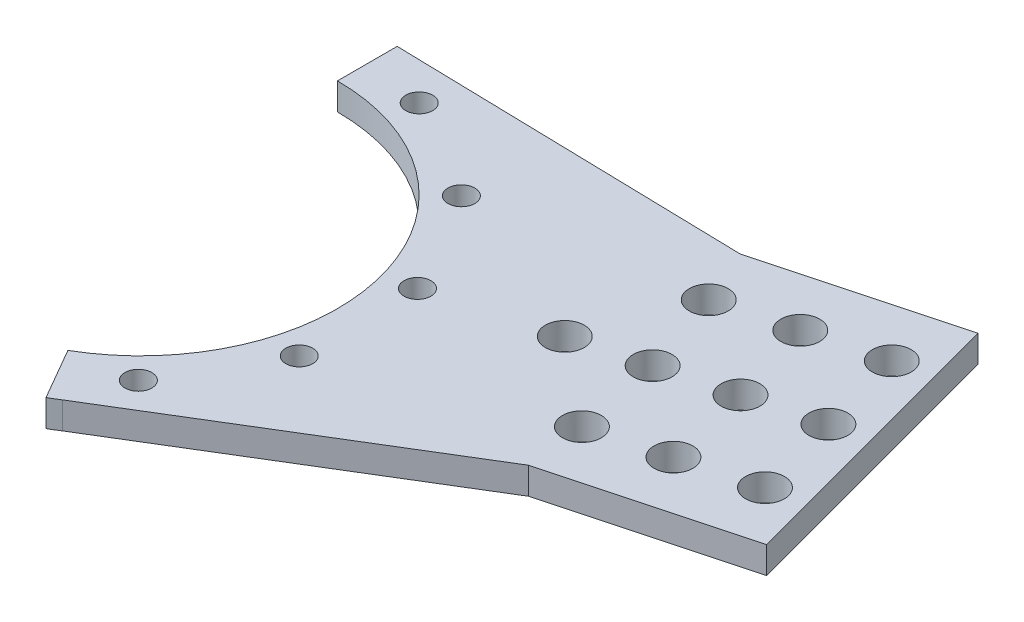
from build123d import *

# Parameters (mm, degrees)
BOSS_EXTRUDE1_DEPTH             = 2.25
BOSS_EXTRUDE2_DEPTH             = 2.25
BOSS_EXTRUDE3_DEPTH             = 2.25
CUT_EXTRUDE1_START              = -5.5
SKETCH2_R                       = 2.25
CUT_EXTRUDE1_DEPTH              = 6.5
CIRPATTERN1_COUNT               = 3
CIRPATTERN1_ANGLE               = 60
CIRPATTERN1_THE_OTHER_WAY_COUNT = 3
CIRPATTERN1_THE_OTHER_WAY_ANGLE = 60
CUT_EXTRUDE2_START              = -5.5
SKETCH6_R                       = 3.25
CUT_EXTRUDE2_DEPTH              = 6.5
LPATTERN1_COUNT                 = 3
LPATTERN1_PITCH                 = 12.5
SKETCH7_R                       = 3.25
CUT_EXTRUDE3_DEPTH              = 10
LPATTERN2_COUNT                 = 4
LPATTERN2_PITCH                 = 12


with BuildPart() as part:
    # Sketch1 → Boss-Extrude1 (new body, symmetric)
    with BuildSketch(Plane(origin=(0, 0, 0), x_dir=(1, 0, 0), z_dir=(0, 1, 0))):
        with BuildLine():
            Line((0, 33), (0, 43))
            ThreePointArc((0, 43), (41.53481053, 11.129218939), (21.5, -37.239092363))
            Line((21.5, -37.239092363), (16.5, -28.578838325))
            ThreePointArc((16.5, -28.578838325), (31.875552268, 8.541028488), (0, 33))
        make_face()
    extrude(amount=BOSS_EXTRUDE1_DEPTH, both=True)

    # Sketch4 → Boss-Extrude2 (add, symmetric)
    with BuildSketch(Plane(origin=(0, 0, 0), x_dir=(1, 0, 0), z_dir=(0, 1, 0))):
        Polygon((90.122106501, 50.030050167), (25.40507614, 32.689174146), (38.346028395, -15.607117169), (103.063058756, 1.733758853), align=None)
    extrude(amount=BOSS_EXTRUDE2_DEPTH, both=True)

    # Sketch5 → Boss-Extrude3 (add, symmetric)
    with BuildSketch(Plane(origin=(0, 0, 0), x_dir=(1, 0, 0), z_dir=(0, 1, 0))):
        Polygon((0, 43), (58.722616268, 41.616582117), (27.323126035, 33.203114066), align=None)
        Polygon((71.663568523, -6.679709198), (40.26407829, -15.093177248), (21.5, -37.239092363), align=None)
    extrude(amount=BOSS_EXTRUDE3_DEPTH, both=True)

    # Sketch2 → Cut-Extrude1 (cut)
    with BuildSketch(Plane(origin=(0, 2.25, 0), x_dir=(1, 0, 0), z_dir=(0, 1, 0)).offset(CUT_EXTRUDE1_START)):
        with Locations((36.757261811, 9.638656763)):
            Circle(SKETCH2_R)
    cut_extrude1 = extrude(amount=CUT_EXTRUDE1_DEPTH, mode=Mode.SUBTRACT)

    # CirPattern1: Cut-Extrude1 ×3 about axis
    cirpattern1_axis = Axis((0, 0, 0), (0, -1, 0))
    for i in range(1, CIRPATTERN1_COUNT):
        add(cut_extrude1.rotate(cirpattern1_axis, i * CIRPATTERN1_ANGLE / (CIRPATTERN1_COUNT - 1)), mode=Mode.SUBTRACT)

    # CirPattern1 the other way: Cut-Extrude1 ×3 about axis
    cirpattern1_the_other_way_axis = Axis((0, 0, 0), (0, 1, 0))
    for i in range(1, CIRPATTERN1_THE_OTHER_WAY_COUNT):
        add(cut_extrude1.rotate(cirpattern1_the_other_way_axis, i * CIRPATTERN1_THE_OTHER_WAY_ANGLE / (CIRPATTERN1_THE_OTHER_WAY_COUNT - 1)), mode=Mode.SUBTRACT)

    # Sketch6 → Cut-Extrude2 (cut)
    with BuildSketch(Plane(origin=(0, 2.25, 0), x_dir=(1, 0, 0), z_dir=(0, 1, 0)).offset(CUT_EXTRUDE2_START)):
        with Locations((94.679313348, 9.840102845)):
            Circle(SKETCH6_R)
        with Locations((86.914741995, 38.817877634)):
            Circle(SKETCH6_R)
    cut_extrude2 = extrude(amount=CUT_EXTRUDE2_DEPTH, mode=Mode.SUBTRACT)

    # LPattern1: Cut-Extrude2 ×3
    with Locations(*[Vector(-0.965925826, 0, 0.258819045) * (i * LPATTERN1_PITCH) for i in range(1, LPATTERN1_COUNT)]):
        add(cut_extrude2, mode=Mode.SUBTRACT)

    # Sketch7 → Cut-Extrude3 (cut)
    with BuildSketch(Plane(origin=(0, 2.25, 0), x_dir=(1, 0, 0), z_dir=(0, 1, 0))):
        with Locations((90.797027671, 24.32899024)):
            Circle(SKETCH7_R)
    cut_extrude3 = extrude(amount=-CUT_EXTRUDE3_DEPTH, mode=Mode.SUBTRACT)

    # LPattern2: Cut-Extrude3 ×4
    with Locations(*[Vector(-0.965925826, 0, 0.258819045) * (i * LPATTERN2_PITCH) for i in range(1, LPATTERN2_COUNT)]):
        add(cut_extrude3, mode=Mode.SUBTRACT)


solid = part.part
